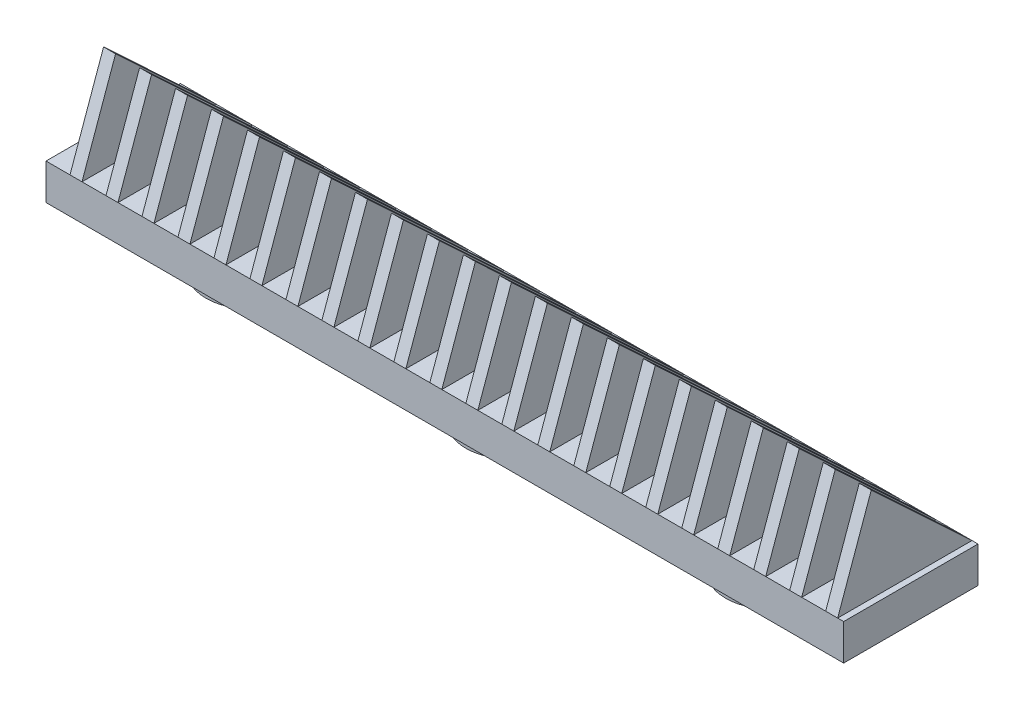
from build123d import *

# Parameters (mm, degrees)
SKETCH1_W           = 211.1375
SKETCH1_H           = 35.56
BOSS_EXTRUDE1_DEPTH = 9.525
SKETCH6_R           = 12.192
BOSS_EXTRUDE4_DEPTH = 6.35
BOSS_EXTRUDE5_DEPTH = 3.175
LPATTERN1_COUNT     = 22
LPATTERN1_PITCH     = 9.525


with BuildPart() as part:
    # Sketch1 → Boss-Extrude1 (new body)
    with BuildSketch(Plane(origin=(0, 0, 0), x_dir=(1, 0, 0), z_dir=(0, 1, 0))):
        with Locations((-105.56875, 17.78)):
            Rectangle(SKETCH1_W, SKETCH1_H)
    extrude(amount=BOSS_EXTRUDE1_DEPTH)

    # Sketch6 → Boss-Extrude4 (add)
    with BuildSketch(Plane(origin=(0, 0, 0), x_dir=(-1, 0, 0), z_dir=(0, -1, 0))):
        with Locations((105.56875, 17.78)):
            Circle(SKETCH6_R)
        with Locations((36.79825, 17.78)):
            Circle(SKETCH6_R)
        with Locations((174.33925, 17.78)):
            Circle(SKETCH6_R)
    extrude(amount=BOSS_EXTRUDE4_DEPTH)

    # Sketch9 → Boss-Extrude5 (add)
    with BuildSketch(Plane.ZY.offset(204.7875)):
        Polygon((-35.56, 9.525), (0, 9.525), (-8.89, 34.417), align=None)
    boss_extrude5 = extrude(amount=-BOSS_EXTRUDE5_DEPTH)

    # LPattern1: Boss-Extrude5 ×22
    with Locations(*[(i * LPATTERN1_PITCH, 0, 0) for i in range(1, LPATTERN1_COUNT)]):
        add(boss_extrude5)


solid = part.part
